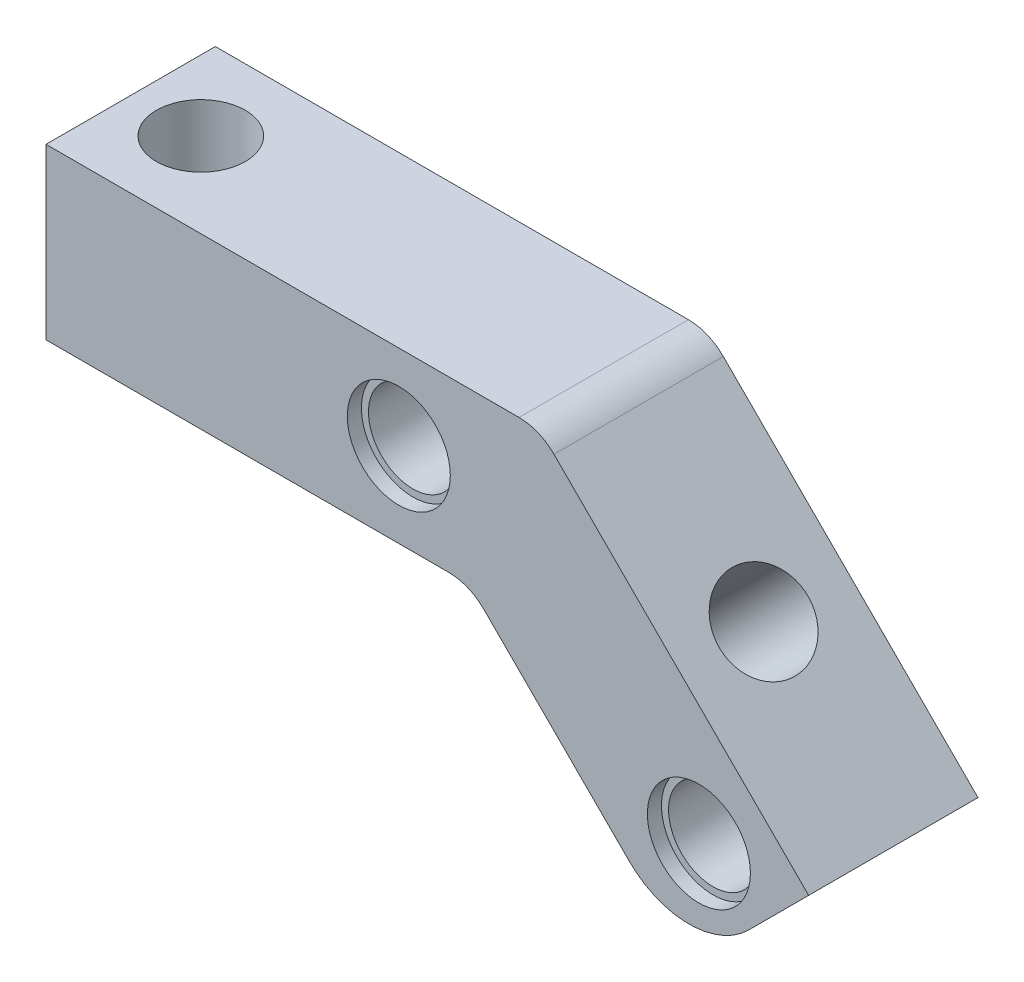
from build123d import *

# Parameters (mm, degrees)
BOSS_EXTRU_1_DEPTH           = 12
ESQUISSE2_R                  = 3.15
ENL_V_MAT_EXTRU_1_DEPTH      = 1
ENL_V_MAT_EXTRU_1_DEPTH_BACK = 13
ESQUISSE3_R                  = 3.15
ENL_V_MAT_EXTRU_2_DEPTH      = 12
ESQUISSE4_R                  = 3.15
ENL_V_MAT_EXTRU_3_DEPTH      = 1
ENL_V_MAT_EXTRU_3_DEPTH_BACK = 28.556349186
ESQUISSE5_R                  = 3.65
ENL_V_MAT_EXTRU_4_DEPTH      = 1
ESQUISSE6_R                  = 3.65
ENL_V_MAT_EXTRU_5_DEPTH      = 1
ESQUISSE7_R                  = 3.65
ENL_V_MAT_EXTRU_6_DEPTH      = 1
ESQUISSE8_R                  = 3.65
ENL_V_MAT_EXTRU_7_DEPTH      = 1
CONG_1_R                     = 3.5
CONG_2_R                     = 6


with BuildPart() as part:
    # Esquisse1 → Boss.-Extru.1 (new body)
    with BuildSketch(Plane.XY):
        Polygon((0, 0), (30, 0), (45.556349186, -15.556349186), (54.04163056, -7.071067812), (34.970562748, 12), (0, 12), align=None)
    extrude(amount=BOSS_EXTRU_1_DEPTH)

    # Esquisse2 → Enlèv. mat.-Extru.1 (cut, two sides)
    with BuildSketch(Plane.XY.offset(12)) as enl_v_mat_extru_1_sk:
        with Locations((25, 6)):
            Circle(ESQUISSE2_R)
        with Locations((46.263455967, -7.778174593)):
            Circle(ESQUISSE2_R)
    extrude(amount=ENL_V_MAT_EXTRU_1_DEPTH, mode=Mode.SUBTRACT)
    extrude(enl_v_mat_extru_1_sk.sketch, amount=-ENL_V_MAT_EXTRU_1_DEPTH_BACK, mode=Mode.SUBTRACT)

    # Esquisse3 → Enlèv. mat.-Extru.2 (cut)
    with BuildSketch(Plane(origin=(23.485281374, 23.485281374, 0), x_dir=(0, 0, -1), z_dir=(0.707106781, 0.707106781, 0))):
        with Locations((-6, -30.213203436)):
            Circle(ESQUISSE3_R)
    extrude(amount=-ENL_V_MAT_EXTRU_2_DEPTH, mode=Mode.SUBTRACT)

    # Esquisse4 → Enlèv. mat.-Extru.3 (cut, two sides)
    with BuildSketch(Plane(origin=(0, 12, 0), x_dir=(1, 0, 0), z_dir=(0, 1, 0))) as enl_v_mat_extru_3_sk:
        with Locations((4.970562748, -6)):
            Circle(ESQUISSE4_R)
    extrude(amount=ENL_V_MAT_EXTRU_3_DEPTH, mode=Mode.SUBTRACT)
    extrude(enl_v_mat_extru_3_sk.sketch, amount=-ENL_V_MAT_EXTRU_3_DEPTH_BACK, mode=Mode.SUBTRACT)

    # Esquisse5 → Enlèv. mat.-Extru.4 (cut)
    with BuildSketch(Plane.XY.offset(12)):
        with Locations((25, 6)):
            Circle(ESQUISSE5_R)
        with Locations((46.263455967, -7.778174593)):
            Circle(ESQUISSE5_R)
    extrude(amount=-ENL_V_MAT_EXTRU_4_DEPTH, mode=Mode.SUBTRACT)

    # Esquisse6 → Enlèv. mat.-Extru.5 (cut)
    with BuildSketch(Plane(origin=(0, 0, 0), x_dir=(-1, 0, 0), z_dir=(0, 0, -1))):
        with Locations((-25, 6)):
            Circle(ESQUISSE6_R)
        with Locations((-46.263455967, -7.778174593)):
            Circle(ESQUISSE6_R)
    extrude(amount=-ENL_V_MAT_EXTRU_5_DEPTH, mode=Mode.SUBTRACT)

    # Esquisse7 → Enlèv. mat.-Extru.6 (cut)
    with BuildSketch(Plane(origin=(15, 15, 0), x_dir=(0, 0, 1), z_dir=(-0.707106781, -0.707106781, 0))):
        with Locations((6, -30.213203436)):
            Circle(ESQUISSE7_R)
    extrude(amount=-ENL_V_MAT_EXTRU_6_DEPTH, mode=Mode.SUBTRACT)

    # Esquisse8 → Enlèv. mat.-Extru.7 (cut)
    with BuildSketch(Plane.XZ):
        with Locations((4.970562748, 6)):
            Circle(ESQUISSE8_R)
    extrude(amount=-ENL_V_MAT_EXTRU_7_DEPTH, mode=Mode.SUBTRACT)

    # Congé1
    cong_1_edges = [part.edges().sort_by_distance(p)[0] for p in [
        (34.970562748, 12, 6),
        (30, 0, 6),
    ]]
    fillet(cong_1_edges, radius=CONG_1_R)

    # Congé2
    cong_2_edges = [part.edges().sort_by_distance(p)[0] for p in [
        (45.556349186, -15.556349186, 6),
    ]]
    fillet(cong_2_edges, radius=CONG_2_R)


solid = part.part
